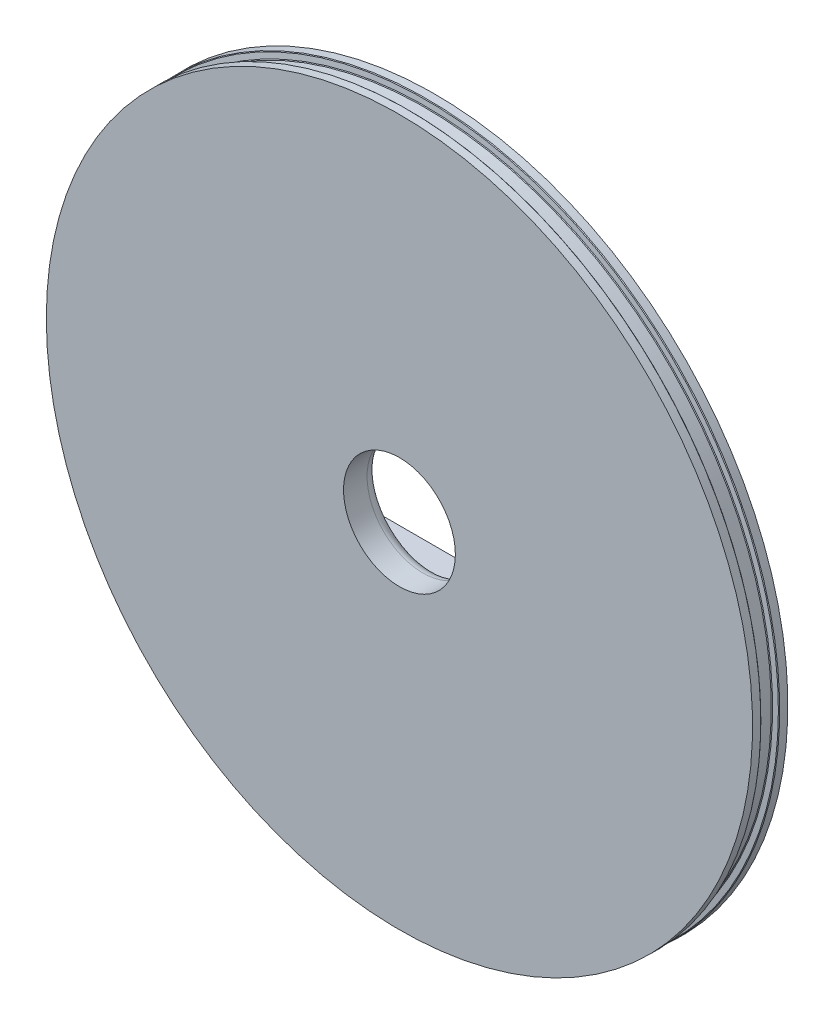
from build123d import *
from OCP.BRepFilletAPI import BRepFilletAPI_MakeChamfer

# Parameters (mm, degrees)
SKETCH1_R           = 76.2
BOSS_EXTRUDE1_DEPTH = 7.62
CHAMFER1_SIZE       = 0.13
CHAMFER1_SIZE2      = 0.143008173
SKETCH3_R           = 12.065
CUT_EXTRUDE1_DEPTH  = 7.62
SKETCH4_W           = 68.58
SKETCH4_H           = 52.580948596
SKETCH4_W_2         = 60.96
SKETCH4_H_2         = 44.960948596
BOSS_EXTRUDE2_DEPTH = 20.828
SKETCH5_W           = 3.81
SKETCH5_H           = 39.880948596
CUT_EXTRUDE3_DEPTH  = 20.828
FILLET1_R           = 2.54


with BuildPart() as part:
    # Sketch1 → Boss-Extrude1 (new body)
    with BuildSketch(Plane.XY):
        with Locations(Location((0, 0, 0), (0, 0, 180))):
            Circle(SKETCH1_R)
    extrude(amount=BOSS_EXTRUDE1_DEPTH)

    # Sketch2 → Cut-Revolve1 (revolve, cut)
    with BuildSketch(Plane(origin=(0, 0, 0), x_dir=(0, 0, -1), z_dir=(1, 0, 0)), mode=Mode.PRIVATE) as cut_revolve1_sk:
        Polygon((-1.907556125, 76.2), (-2.032, 74.7776), (-5.588, 74.7776), (-5.712443875, 76.2), align=None)
    revolve(cut_revolve1_sk.sketch.rotate(Axis((0, 0, 0), (0, 0, 1)), 90), axis=Axis((0, 0, 0), (0, 0, 1)), mode=Mode.SUBTRACT)

    # Chamfer1: one chamfer whose edges measure the first distance from different faces: ONE call of the kernel's chamfer builder (chamfer() names one face for all edges)
    chamfer1_edges_1 = [part.edges().sort_by_distance(p)[0] for p in [
        (76.2, 0, 5.712443875),
    ]]
    chamfer1_side_1 = [part.faces().sort_by_distance(p)[0] for p in [
        (76.2, 0, 6.666221937),
    ]]
    chamfer1_edges_2 = [part.edges().sort_by_distance(p)[0] for p in [
        (76.2, 0, 1.907556125),
    ]]
    chamfer1_side_2 = [part.faces().sort_by_distance(p)[0] for p in [
        (75.4888, 0, 1.969778063),
    ]]
    chamfer1_edges_3 = [part.edges().sort_by_distance(p)[0] for p in [
        (74.7776, 0, 2.032),
    ]]
    chamfer1_side_3 = [part.faces().sort_by_distance(p)[0] for p in [
        (74.7776, 0, 3.81),
    ]]
    chamfer1_edges_4 = [part.edges().sort_by_distance(p)[0] for p in [
        (74.7776, 0, 5.588),
    ]]
    chamfer1_side_4 = [part.faces().sort_by_distance(p)[0] for p in [
        (75.4888, 0, 5.650221937),
    ]]
    chamfer1 = BRepFilletAPI_MakeChamfer(part.part.solid().wrapped)
    for e in chamfer1_edges_1:
        chamfer1.Add(CHAMFER1_SIZE, CHAMFER1_SIZE2, e.wrapped, chamfer1_side_1[0].wrapped)  # the first distance lies on this face
    for e in chamfer1_edges_2:
        chamfer1.Add(CHAMFER1_SIZE, CHAMFER1_SIZE2, e.wrapped, chamfer1_side_2[0].wrapped)  # the first distance lies on this face
    for e in chamfer1_edges_3:
        chamfer1.Add(CHAMFER1_SIZE, CHAMFER1_SIZE2, e.wrapped, chamfer1_side_3[0].wrapped)  # the first distance lies on this face
    for e in chamfer1_edges_4:
        chamfer1.Add(CHAMFER1_SIZE, CHAMFER1_SIZE2, e.wrapped, chamfer1_side_4[0].wrapped)  # the first distance lies on this face
    add(Compound.cast(chamfer1.Shape()), mode=Mode.REPLACE)

    # Sketch3 → Cut-Extrude1 (cut)
    with BuildSketch(Plane.XY.offset(7.62)):
        Circle(SKETCH3_R)
    extrude(amount=-CUT_EXTRUDE1_DEPTH, mode=Mode.SUBTRACT)

    # Sketch4 → Boss-Extrude2 (add)
    with BuildSketch(Plane(origin=(0, 0, 0), x_dir=(-1, 0, 0), z_dir=(0, 0, -1))):
        with Locations((14.605, -6.605474298)):
            Rectangle(SKETCH4_W, SKETCH4_H)
        with Locations((14.605, -6.605474298)):
            Rectangle(SKETCH4_W_2, SKETCH4_H_2, mode=Mode.SUBTRACT)
    extrude(amount=BOSS_EXTRUDE2_DEPTH)

    # Sketch5 → Cut-Extrude3 (cut)
    with BuildSketch(Plane(origin=(0, 0, -20.828), x_dir=(-1, 0, 0), z_dir=(0, 0, -1))):
        with Locations((-17.78, -9.145474298)):
            Rectangle(SKETCH5_W, SKETCH5_H)
    extrude(amount=-CUT_EXTRUDE3_DEPTH, mode=Mode.SUBTRACT)

    # Fillet1
    fillet1_edges = [part.edges().sort_by_distance(p)[0] for p in [
        (-12.065, 0, 0),
        (19.685, -30.990948596, 0),
        (17.78, 10.795, 0),
        (-14.605, -32.895948596, 0),
        (-14.605, 19.685, 0),
        (19.685, 19.685, -10.414),
        (19.685, 15.24, -20.828),
        (19.685, 10.795, -10.414),
        (19.685, 15.24, 0),
        (-48.895, -32.895948596, -10.414),
        (-48.895, -6.605474298, -20.828),
        (-48.895, 19.685, -10.414),
        (-48.895, -6.605474298, 0),
        (19.685, -32.895948596, -10.414),
    ]]
    fillet(fillet1_edges, radius=FILLET1_R)


solid = part.part
